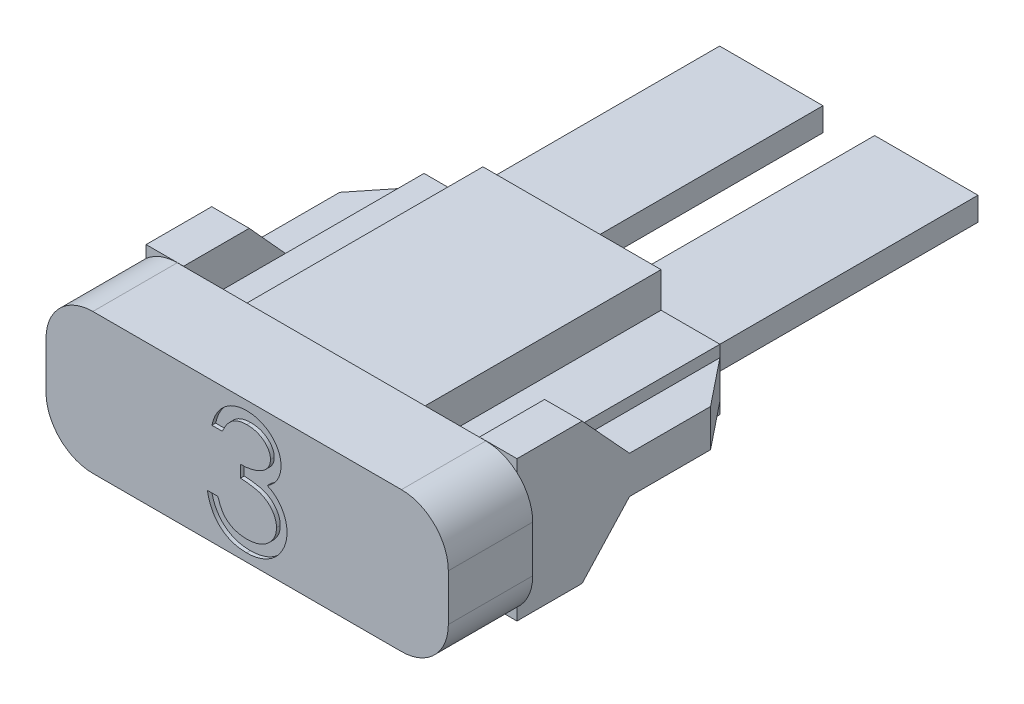
from build123d import *

# Parameters (mm, degrees)
EXTRUDE1_DEPTH      = 2.286
EXTRUDE2_DEPTH      = 6.514
EXTRUDE3_DEPTH      = 1.016
EXTRUDE4_DEPTH      = 1.016
CHAMFER1_SIZE       = 1.016
CHAMFER1_SIZE2      = 1.27
SKETCH8_W           = 2.8
SKETCH8_H           = 14.014
BLADE_DEPTH         = 0.635
CUT_EXTRUDE_3_DEPTH = 0.1016


with BuildPart() as part:
    # Sketch1 → Extrude1 (new body)
    with BuildSketch(Plane.XY):
        with BuildLine():
            Line((1.27, 0), (9.63, 0))
            ThreePointArc((9.63, 0), (10.528025612, 0.371974388), (10.9, 1.27))
            Line((10.9, 1.27), (10.9, 2.53))
            ThreePointArc((10.9, 2.53), (10.528025612, 3.428025612), (9.63, 3.8))
            Line((9.63, 3.8), (1.27, 3.8))
            ThreePointArc((1.27, 3.8), (0.371974388, 3.428025612), (0, 2.53))
            Line((0, 2.53), (0, 1.27))
            ThreePointArc((0, 1.27), (0.371974388, 0.371974388), (1.27, 0))
        make_face()
    extrude(amount=EXTRUDE1_DEPTH)

    # Sketch2 → Extrude2 (add)
    with BuildSketch(Plane(origin=(0, 0, 0), x_dir=(-1, 0, 0), z_dir=(0, 0, -1))):
        Polygon((-7.863, 3.678), (-7.863, 2.7255), (-9.458, 2.7255), (-9.458, 1.0745), (-7.863, 1.0745), (-7.863, 0.122), (-3.037, 0.122), (-3.037, 1.0745), (-1.442, 1.0745), (-1.442, 2.7255), (-3.037, 2.7255), (-3.037, 3.678), align=None)
        Polygon((-3.545, 1.5825), (-3.545, 0.63), (-7.355, 0.63), (-7.355, 1.5825), (-8.95, 1.5825), (-8.95, 2.2175), (-7.355, 2.2175), (-7.355, 3.17), (-3.545, 3.17), (-3.545, 2.2175), (-1.95, 2.2175), (-1.95, 1.5825), align=None, mode=Mode.SUBTRACT)
    extrude(amount=EXTRUDE2_DEPTH)

    # Sketch3 → Extrude3 (add)
    with BuildSketch(Plane.ZY.offset(-1.442)):
        Polygon((-6.514, 2.408), (-3.048, 2.408), (-1.778, 3.805), (0, 3.805), (0, -0.005), (-1.778, -0.005), (-3.048, 1.392), (-6.514, 1.392), align=None)
    extrude(amount=EXTRUDE3_DEPTH)

    # Sketch4 → Extrude4 (add)
    with BuildSketch(Plane(origin=(9.458, 0, 0), x_dir=(0, 0, -1), z_dir=(1, 0, 0))):
        Polygon((3.048, 2.408), (6.514, 2.408), (6.514, 1.392), (3.048, 1.392), (1.764, -0.005), (0, -0.005), (0, 3.805), (1.764, 3.805), align=None)
    extrude(amount=EXTRUDE4_DEPTH)

    # Chamfer1
    chamfer1_edges = [part.edges().sort_by_distance(p)[0] for p in [
        (0.426, 1.9, -6.514),
        (10.474, 1.9, -6.514),
    ]]
    chamfer1_side = [part.faces().sort_by_distance(p)[0] for p in [
        (0.934, 1.498586791, -6.514),
    ]]
    chamfer(chamfer1_edges, length=CHAMFER1_SIZE, length2=CHAMFER1_SIZE2, reference=chamfer1_side[0])

    # Sketch8 → Blade (add)
    with BuildSketch(Plane(origin=(0, 1.5825, 0), x_dir=(-1, 0, 0), z_dir=(0, 1, 0))):
        with Locations((-3.35, -7.007)):
            Rectangle(SKETCH8_W, SKETCH8_H)
        with Locations((-7.55, -7.007)):
            Rectangle(SKETCH8_W, SKETCH8_H)
    extrude(amount=BLADE_DEPTH)

    # Sketch15 → "3" (cut)
    with BuildSketch(Plane.XY.offset(2.286)):
        with BuildLine():
            Line((4.779166667, 2.742307692), (4.494230769, 2.742307692))
            add(Edge.make_bspline(
                [(4.494230769, 2.742307692), (4.501950147, 2.774268588), (4.5170409, 2.836749526), (4.548516556, 2.92601897), (4.58280588, 3.010495307), (4.623980282, 3.088596746), (4.668891795, 3.161892893), (4.720347407, 3.228721313), (4.775973155, 3.290781646), (4.837500074, 3.345857226), (4.902023931, 3.39572988), (4.970453907, 3.438252254), (5.041413247, 3.474832021), (5.115393589, 3.504967517), (5.192615187, 3.527669242), (5.272379917, 3.544140059), (5.354896806, 3.554836284), (5.410910692, 3.55588019), (5.439352965, 3.556410256)],
                knots=[0, 0, 0, 0, 1.162005537, 2.271625781, 3.343758855, 4.383309926, 5.390229558, 6.379919256, 7.361854164, 8.333198761, 9.295911338, 10.242430842, 11.177959212, 12.116337295, 13.062827104, 14.020064771, 14.994644689, 16, 16, 16, 16], degree=3))
            add(Edge.make_bspline(
                [(5.439352965, 3.556410256), (5.480793738, 3.555159098), (5.562771341, 3.552684071), (5.68320639, 3.530083118), (5.799345005, 3.494318891), (5.909915965, 3.444903438), (6.012621258, 3.383954947), (6.10400337, 3.311415507), (6.182823662, 3.228684712), (6.248949276, 3.137305886), (6.300724454, 3.03964696), (6.338902807, 2.939135389), (6.362145332, 2.8360096), (6.365157551, 2.766379783), (6.366666667, 2.731495393)],
                knots=[0, 0, 0, 0, 1.083050992, 2.142477498, 3.193116406, 4.255571735, 5.30263384, 6.308962982, 7.297363603, 8.282367274, 9.249857812, 10.179914175, 11.08814088, 12, 12, 12, 12], degree=3))
            add(Edge.make_bspline(
                [(6.366666667, 2.731495393), (6.365611123, 2.697924943), (6.363545589, 2.632232783), (6.346007156, 2.536328282), (6.316492118, 2.445939116), (6.275607404, 2.360684776), (6.222683284, 2.281105814), (6.158573052, 2.207023185), (6.082824208, 2.138108306), (6.025421172, 2.098629927), (5.995868389, 2.078305288)],
                knots=[0, 0, 0, 0, 1.024540389, 2.004866551, 2.965041327, 3.920577974, 4.882998113, 5.874504559, 6.905732034, 8, 8, 8, 8], degree=3))
            add(Edge.make_bspline(
                [(5.995868389, 2.078305288), (6.02964291, 2.061996519), (6.096560003, 2.029684128), (6.187773697, 1.966314977), (6.27057577, 1.893148148), (6.316752715, 1.83605017), (6.339953926, 1.807361779)],
                knots=[0, 0, 0, 0, 1.015518401, 2.012035669, 3.001164323, 4, 4, 4, 4], degree=3))
            add(Edge.make_bspline(
                [(6.339953926, 1.807361779), (6.35523143, 1.786445104), (6.385536257, 1.74495428), (6.422942777, 1.678246236), (6.456878188, 1.610798814), (6.483321601, 1.54080421), (6.503799323, 1.46907369), (6.518437009, 1.395484088), (6.527530337, 1.319975311), (6.528832588, 1.268891847), (6.529487179, 1.243214143)],
                knots=[0, 0, 0, 0, 1.025084078, 2.033381695, 3.024893161, 4.013698104, 4.991890475, 5.976764909, 6.982997093, 8, 8, 8, 8], degree=3))
            add(Edge.make_bspline(
                [(6.529487179, 1.243214143), (6.527859299, 1.198755324), (6.5246112, 1.110046911), (6.495578933, 0.978987699), (6.450572636, 0.850875994), (6.386658129, 0.728343818), (6.308764032, 0.613698758), (6.216092745, 0.511122392), (6.109697218, 0.422949372), (5.991037808, 0.349280094), (5.862480127, 0.290390265), (5.724979411, 0.249516727), (5.580516862, 0.222895713), (5.481450242, 0.220041054), (5.431084736, 0.218589744)],
                knots=[0, 0, 0, 0, 0.955779014, 1.907060117, 2.875433937, 3.871313158, 4.872415639, 5.851225146, 6.836215519, 7.83643374, 8.849228613, 9.86973379, 10.916971861, 12, 12, 12, 12], degree=3))
            add(Edge.make_bspline(
                [(5.431084736, 0.218589744), (5.397140085, 0.219377337), (5.330348331, 0.220927058), (5.232156014, 0.231521218), (5.138428473, 0.25087058), (5.04903898, 0.276908578), (4.963908126, 0.309921087), (4.883295688, 0.35103162), (4.806705713, 0.399392769), (4.73486095, 0.455575381), (4.667769964, 0.518423453), (4.607215707, 0.589052698), (4.552188609, 0.666157486), (4.504162072, 0.750633401), (4.460948551, 0.841388741), (4.425405826, 0.939585593), (4.394122489, 1.044346099), (4.379577846, 1.117350906), (4.372115385, 1.154807692)],
                knots=[0, 0, 0, 0, 1.048658725, 2.063410685, 3.046034179, 4.001477787, 4.936774919, 5.862367409, 6.792675028, 7.730719943, 8.675894397, 9.627829632, 10.600096036, 11.597688215, 12.626045268, 13.701542398, 14.82072376, 16, 16, 16, 16], degree=3))
            Line((4.372115385, 1.154807692), (4.657051282, 1.154807692))
            add(Edge.make_bspline(
                [(4.657051282, 1.154807692), (4.664474696, 1.130361087), (4.678913882, 1.082810317), (4.703492281, 1.014375183), (4.731494214, 0.951638949), (4.761533849, 0.894141403), (4.793082868, 0.841316295), (4.828384264, 0.794560456), (4.864823417, 0.751820237), (4.892291116, 0.727740482), (4.905734175, 0.715955529)],
                knots=[0, 0, 0, 0, 1.198163088, 2.33053128, 3.407730985, 4.417276592, 5.372219308, 6.28897303, 7.162600585, 8, 8, 8, 8], degree=3))
            add(Edge.make_bspline(
                [(4.905734175, 0.715955529), (4.923511069, 0.702250112), (4.959009985, 0.674881583), (5.01685688, 0.639955106), (5.077694312, 0.60969189), (5.142840481, 0.586574537), (5.210889594, 0.567000516), (5.282941561, 0.554191188), (5.358360708, 0.545402633), (5.40985718, 0.544627088), (5.436172877, 0.544230769)],
                knots=[0, 0, 0, 0, 0.946170439, 1.889420265, 2.845303464, 3.807233317, 4.801018734, 5.828864929, 6.890507805, 8, 8, 8, 8], degree=3))
            add(Edge.make_bspline(
                [(5.436172877, 0.544230769), (5.465884983, 0.544789483), (5.523984441, 0.545882), (5.608761349, 0.555929249), (5.689413105, 0.570561838), (5.765044259, 0.593161472), (5.836645505, 0.621084102), (5.903213144, 0.656143727), (5.965621041, 0.697277867), (6.023069858, 0.744031247), (6.074727569, 0.795213603), (6.12021127, 0.848746889), (6.158877927, 0.904405392), (6.190068745, 0.962497116), (6.214698172, 1.022781502), (6.231465076, 1.085427726), (6.243123236, 1.149923103), (6.244072663, 1.193764382), (6.244551282, 1.215865385)],
                knots=[0, 0, 0, 0, 1.217147791, 2.380027433, 3.494444702, 4.572153297, 5.609568379, 6.639424714, 7.649109417, 8.668170816, 9.669597737, 10.625200337, 11.543417969, 12.441394052, 13.322311151, 14.205496177, 15.095365482, 16, 16, 16, 16], degree=3))
            add(Edge.make_bspline(
                [(6.244551282, 1.215865385), (6.24316308, 1.245448528), (6.240393583, 1.304467612), (6.219249372, 1.391297126), (6.184470545, 1.474956936), (6.13578191, 1.554019688), (6.07651307, 1.627294971), (6.00723919, 1.692674101), (5.927385012, 1.746621969), (5.853888416, 1.783895251), (5.788787167, 1.809328883), (5.73307464, 1.826269744), (5.670702578, 1.840614988), (5.602425248, 1.85396112), (5.527728187, 1.865319772), (5.446692718, 1.874791991), (5.35930242, 1.882371206), (5.298804005, 1.885755843), (5.267628205, 1.8875)],
                knots=[0, 0, 0, 0, 1.07054697, 2.135767047, 3.216561865, 4.33974944, 5.486079747, 6.621378074, 7.775625952, 8.963672916, 9.598146892, 10.304877434, 11.070270905, 11.915000392, 12.823868403, 13.805723172, 14.86925407, 16, 16, 16, 16], degree=3))
            Line((5.267628205, 1.8875), (5.267628205, 2.213141026))
            add(Edge.make_bspline(
                [(5.267628205, 2.213141026), (5.306908548, 2.213807598), (5.383849091, 2.215113248), (5.496238925, 2.230904801), (5.603711144, 2.25274937), (5.703883974, 2.286209509), (5.795186735, 2.325071778), (5.874398089, 2.370294854), (5.940408287, 2.420563948), (5.992896544, 2.476654958), (6.032383773, 2.53681218), (6.061255225, 2.599510862), (6.078309807, 2.665300546), (6.080586433, 2.71019928), (6.081730769, 2.732767428)],
                knots=[0, 0, 0, 0, 1.321986639, 2.589447074, 3.816329219, 5.01088745, 6.139805852, 7.153945165, 8.075214402, 8.924034688, 9.728124013, 10.488707548, 11.240355623, 12, 12, 12, 12], degree=3))
            add(Edge.make_bspline(
                [(6.081730769, 2.732767428), (6.081354839, 2.749347954), (6.080606944, 2.782334124), (6.071175128, 2.83052615), (6.057001891, 2.877244866), (6.037516708, 2.922291594), (6.011436171, 2.965353913), (5.980225026, 3.006798956), (5.943061106, 3.046390099), (5.900474879, 3.08329296), (5.85474417, 3.118462197), (5.804624732, 3.148319567), (5.751627745, 3.173851159), (5.695694537, 3.194905493), (5.636643592, 3.210743562), (5.574752357, 3.222115361), (5.509902816, 3.229225234), (5.465659887, 3.230248868), (5.443169071, 3.230769231)],
                knots=[0, 0, 0, 0, 0.884392785, 1.759457502, 2.611959086, 3.489218968, 4.37281399, 5.2945488, 6.255912374, 7.266815255, 8.301784654, 9.332968512, 10.37626691, 11.440494194, 12.520033166, 13.637162961, 14.798855837, 16, 16, 16, 16], degree=3))
            add(Edge.make_bspline(
                [(5.443169071, 3.230769231), (5.407017915, 3.229507067), (5.336406299, 3.227041767), (5.234611338, 3.205449033), (5.1399788, 3.170997486), (5.067644438, 3.129873961), (5.014229531, 3.089278925), (4.976059737, 3.053825617), (4.938576132, 3.014425841), (4.904244696, 2.968652887), (4.869524732, 2.919606584), (4.837915736, 2.864793673), (4.807200159, 2.805643972), (4.788692131, 2.763828647), (4.779166667, 2.742307692)],
                knots=[0, 0, 0, 0, 1.472543308, 2.876219568, 4.221790263, 5.565193594, 6.249813518, 6.953379497, 7.687249741, 8.463570142, 9.283606569, 10.136032583, 11.040678096, 12, 12, 12, 12], degree=3))
        make_face()
    extrude(amount=-CUT_EXTRUDE_3_DEPTH, mode=Mode.SUBTRACT)


solid = part.part
